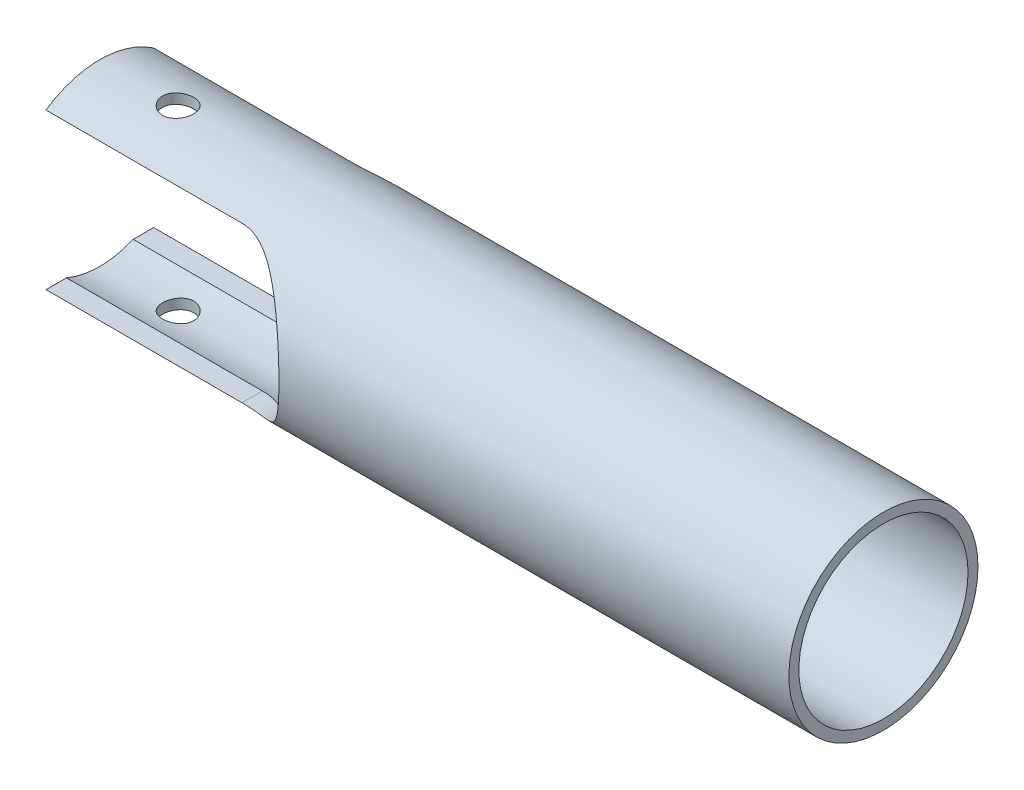
from build123d import *

# Parameters (mm, degrees)
SKETCH1_R               = 1.2065
SKETCH1_R_2             = 1.0795
BOSS_EXTRUDE1_DEPTH     = 10
CUT_EXTRUDE1_DEPTH      = 10
CUT_EXTRUDE1_DEPTH_BACK = 1.5
SKETCH4_R               = 0.1984375
CUT_EXTRUDE2_DEPTH      = 5
CUT_EXTRUDE2_DEPTH_BACK = 5


with BuildPart() as part:
    # Sketch1 → Boss-Extrude1 (new body)
    with BuildSketch(Plane(origin=(0, 0, 0), x_dir=(0, 0, -1), z_dir=(1, 0, 0))):
        Circle(SKETCH1_R)
        Circle(SKETCH1_R_2, mode=Mode.SUBTRACT)
    extrude(amount=BOSS_EXTRUDE1_DEPTH)

    # Sketch2 → Cut-Extrude1 (cut, two sides)
    with BuildSketch(Plane.XY) as cut_extrude1_sk:
        with BuildLine():
            Line((2.5, -0.9921875), (0, -0.9921875))
            Line((0, -0.9921875), (0, 0.9921875))
            Line((0, 0.9921875), (2.5, 0.9921875))
            ThreePointArc((2.5, 0.9921875), (3.4921875, 0), (2.5, -0.9921875))
        make_face()
    extrude(amount=CUT_EXTRUDE1_DEPTH, mode=Mode.SUBTRACT)
    extrude(cut_extrude1_sk.sketch, amount=-CUT_EXTRUDE1_DEPTH_BACK, mode=Mode.SUBTRACT)

    # Sketch4 → Cut-Extrude2 (cut, two sides)
    with BuildSketch(Plane(origin=(0, 0, 0), x_dir=(1, 0, 0), z_dir=(0, 1, 0))) as cut_extrude2_sk:
        with Locations((1, 0)):
            Circle(SKETCH4_R)
    extrude(amount=CUT_EXTRUDE2_DEPTH, mode=Mode.SUBTRACT)
    extrude(cut_extrude2_sk.sketch, amount=-CUT_EXTRUDE2_DEPTH_BACK, mode=Mode.SUBTRACT)


solid = part.part
